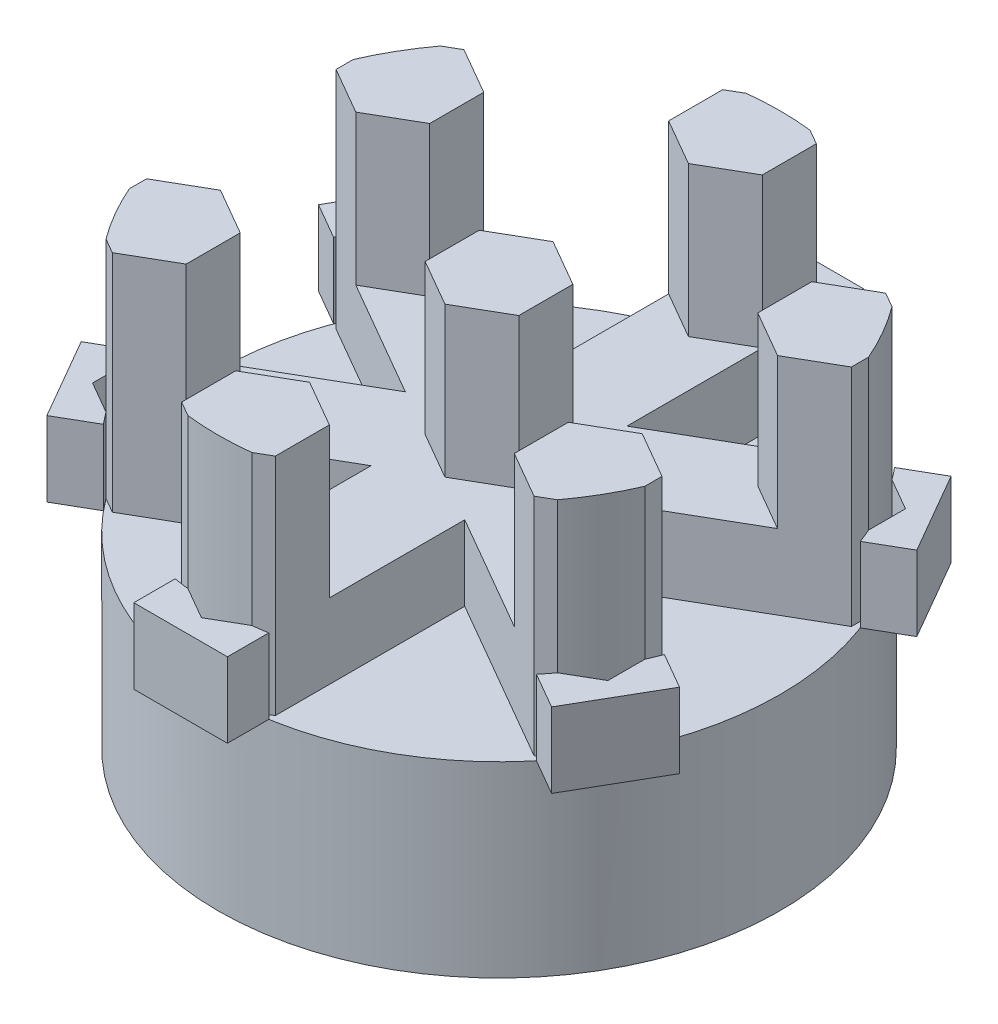
from build123d import *

# Parameters (mm, degrees)
SKETCH1_R           = 75
BOSS_EXTRUDE1_DEPTH = 50
BOSS_EXTRUDE2_DEPTH = 60
BOSS_EXTRUDE3_DEPTH = 20


with BuildPart() as part:
    # Sketch1 → Boss-Extrude1 (new body)
    with BuildSketch(Plane(origin=(0, 0, 0), x_dir=(1, 0, 0), z_dir=(0, 1, 0))):
        Circle(SKETCH1_R)
    extrude(amount=BOSS_EXTRUDE1_DEPTH)

    # Sketch2 → Boss-Extrude2 (add)
    with BuildSketch(Plane(origin=(0, 50, 0), x_dir=(1, 0, 0), z_dir=(0, 1, 0))):
        with BuildLine():
            Line((68.791651246, -29.878231521), (68.791651246, -25.283121635))
            Line((68.791651246, -25.283121635), (56.291651246, -18.06624327))
            Line((56.291651246, -18.06624327), (43.791651246, -25.283121635))
            Line((43.791651246, -25.283121635), (43.791651246, -39.716878365))
            Line((43.791651246, -39.716878365), (56.291651246, -46.93375673))
            Line((56.291651246, -46.93375673), (60.271133141, -44.636201787))
            ThreePointArc((60.271133141, -44.636201787), (64.951905284, -37.5), (68.791651246, -29.878231521))
        make_face()
        with BuildLine():
            Line((43.791651246, 25.283121635), (56.291651246, 18.06624327))
            Line((56.291651246, 18.06624327), (68.791651246, 25.283121635))
            Line((68.791651246, 25.283121635), (68.791651246, 29.878231521))
            ThreePointArc((68.791651246, 29.878231521), (64.951905284, 37.5), (60.271133141, 44.636201787))
            Line((60.271133141, 44.636201787), (56.291651246, 46.93375673))
            Line((56.291651246, 46.93375673), (43.791651246, 39.716878365))
            Line((43.791651246, 39.716878365), (43.791651246, 25.283121635))
        make_face()
        with BuildLine():
            Line((12.5, -72.216878365), (12.5, -57.783121635))
            Line((12.5, -57.783121635), (0, -50.56624327))
            Line((0, -50.56624327), (-12.5, -57.783121635))
            Line((-12.5, -57.783121635), (-12.5, -72.216878365))
            Line((-12.5, -72.216878365), (-8.520518105, -74.514433308))
            ThreePointArc((-8.520518105, -74.514433308), (0, -75), (8.520518105, -74.514433308))
            Line((8.520518105, -74.514433308), (12.5, -72.216878365))
        make_face()
        with BuildLine():
            Line((0, 50.56624327), (12.5, 57.783121635))
            Line((12.5, 57.783121635), (12.5, 72.216878365))
            Line((12.5, 72.216878365), (8.520518105, 74.514433308))
            ThreePointArc((8.520518105, 74.514433308), (0, 75), (-8.520518105, 74.514433308))
            Line((-8.520518105, 74.514433308), (-12.5, 72.216878365))
            Line((-12.5, 72.216878365), (-12.5, 57.783121635))
            Line((-12.5, 57.783121635), (0, 50.56624327))
        make_face()
        with BuildLine():
            Line((-56.291651246, -46.93375673), (-43.791651246, -39.716878365))
            Line((-43.791651246, -39.716878365), (-43.791651246, -25.283121635))
            Line((-43.791651246, -25.283121635), (-56.291651246, -18.06624327))
            Line((-56.291651246, -18.06624327), (-68.791651246, -25.283121635))
            Line((-68.791651246, -25.283121635), (-68.791651246, -29.878231521))
            ThreePointArc((-68.791651246, -29.878231521), (-64.951905284, -37.5), (-60.271133141, -44.636201787))
            Line((-60.271133141, -44.636201787), (-56.291651246, -46.93375673))
        make_face()
        with BuildLine():
            Line((-43.791651246, 25.283121635), (-43.791651246, 39.716878365))
            Line((-43.791651246, 39.716878365), (-56.291651246, 46.93375673))
            Line((-56.291651246, 46.93375673), (-60.271133141, 44.636201787))
            ThreePointArc((-60.271133141, 44.636201787), (-64.951905284, 37.5), (-68.791651246, 29.878231521))
            Line((-68.791651246, 29.878231521), (-68.791651246, 25.283121635))
            Line((-68.791651246, 25.283121635), (-56.291651246, 18.06624327))
            Line((-56.291651246, 18.06624327), (-43.791651246, 25.283121635))
        make_face()
        Polygon((0, 14.43375673), (-12.5, 7.216878365), (-12.5, -7.216878365), (0, -14.43375673), (12.5, -7.216878365), (12.5, 7.216878365), align=None)
    extrude(amount=BOSS_EXTRUDE2_DEPTH)

    # Sketch2_3 → Boss-Extrude3 (add)
    # profile 1 of 7: a face of its own
    with BuildSketch(Plane(origin=(0, 50, 0), x_dir=(1, 0, 0), z_dir=(0, 1, 0))):
        Polygon((43.791651246, -25.283121635), (56.291651246, -18.06624327), (25, 0), (56.291651246, 18.06624327), (43.791651246, 25.283121635), (43.791651246, 39.716878365), (12.5, 21.650635095), (12.5, 57.783121635), (0, 50.56624327), (-12.5, 57.783121635), (-12.5, 21.650635095), (-43.791651246, 39.716878365), (-43.791651246, 25.283121635), (-56.291651246, 18.06624327), (-25, 0), (-56.291651246, -18.06624327), (-43.791651246, -25.283121635), (-43.791651246, -39.716878365), (-12.5, -21.650635095), (-12.5, -57.783121635), (0, -50.56624327), (12.5, -57.783121635), (12.5, -21.650635095), (43.791651246, -39.716878365), align=None)
        Polygon((-12.5, -7.216878365), (-12.5, 7.216878365), (0, 14.43375673), (12.5, 7.216878365), (12.5, -7.216878365), (0, -14.43375673), align=None, mode=Mode.SUBTRACT)
    # profile 2 of 7: a face of its own
    with BuildSketch(Plane(origin=(0, 50, 0), x_dir=(1, 0, 0), z_dir=(0, 1, 0))):
        with BuildLine():
            Line((79.862159322, -31.674682453), (70.293442287, -26.150181097))
            ThreePointArc((70.293442287, -26.150181097), (69.567524038, -28.024268041), (68.791651246, -29.878231521))
            Line((68.791651246, -29.878231521), (68.791651246, -39.716878365))
            Line((68.791651246, -39.716878365), (60.271133141, -44.636201787))
            ThreePointArc((60.271133141, -44.636201787), (59.053490065, -46.235109075), (57.793442287, -47.800816192))
            Line((57.793442287, -47.800816192), (67.362159322, -53.325317547))
            Line((67.362159322, -53.325317547), (79.862159322, -31.674682453))
        make_face()
    # profile 3 of 7: a face of its own
    with BuildSketch(Plane(origin=(0, 50, 0), x_dir=(1, 0, 0), z_dir=(0, 1, 0))):
        with BuildLine():
            ThreePointArc((68.791651246, 29.878231521), (69.567524038, 28.024268041), (70.293442287, 26.150181097))
            Line((70.293442287, 26.150181097), (79.862159322, 31.674682453))
            Line((79.862159322, 31.674682453), (67.362159322, 53.325317547))
            Line((67.362159322, 53.325317547), (57.793442287, 47.800816192))
            ThreePointArc((57.793442287, 47.800816192), (59.053490065, 46.235109075), (60.271133141, 44.636201787))
            Line((60.271133141, 44.636201787), (68.791651246, 39.716878365))
            Line((68.791651246, 39.716878365), (68.791651246, 29.878231521))
        make_face()
    # profile 4 of 7: a face of its own
    with BuildSketch(Plane(origin=(0, 50, 0), x_dir=(1, 0, 0), z_dir=(0, 1, 0))):
        with BuildLine():
            Line((12.5, -85), (12.5, -73.950997289))
            ThreePointArc((12.5, -73.950997289), (10.514033973, -74.259377116), (8.520518105, -74.514433308))
            Line((8.520518105, -74.514433308), (0, -79.43375673))
            Line((0, -79.43375673), (-8.520518105, -74.514433308))
            ThreePointArc((-8.520518105, -74.514433308), (-10.514033973, -74.259377116), (-12.5, -73.950997289))
            Line((-12.5, -73.950997289), (-12.5, -85))
            Line((-12.5, -85), (12.5, -85))
        make_face()
    # profile 5 of 7: a face of its own
    with BuildSketch(Plane(origin=(0, 50, 0), x_dir=(1, 0, 0), z_dir=(0, 1, 0))):
        with BuildLine():
            ThreePointArc((8.520518105, 74.514433308), (10.514033973, 74.259377116), (12.5, 73.950997289))
            Line((12.5, 73.950997289), (12.5, 85))
            Line((12.5, 85), (-12.5, 85))
            Line((-12.5, 85), (-12.5, 73.950997289))
            ThreePointArc((-12.5, 73.950997289), (-10.514033973, 74.259377116), (-8.520518105, 74.514433308))
            Line((-8.520518105, 74.514433308), (0, 79.43375673))
            Line((0, 79.43375673), (8.520518105, 74.514433308))
        make_face()
    # profile 6 of 7: a face of its own
    with BuildSketch(Plane(origin=(0, 50, 0), x_dir=(1, 0, 0), z_dir=(0, 1, 0))):
        with BuildLine():
            Line((-67.362159322, -53.325317547), (-57.793442287, -47.800816192))
            ThreePointArc((-57.793442287, -47.800816192), (-59.053490065, -46.235109075), (-60.271133141, -44.636201787))
            Line((-60.271133141, -44.636201787), (-68.791651246, -39.716878365))
            Line((-68.791651246, -39.716878365), (-68.791651246, -29.878231521))
            ThreePointArc((-68.791651246, -29.878231521), (-69.567524038, -28.024268041), (-70.293442287, -26.150181097))
            Line((-70.293442287, -26.150181097), (-79.862159322, -31.674682453))
            Line((-79.862159322, -31.674682453), (-67.362159322, -53.325317547))
        make_face()
    # profile 7 of 7: a face of its own
    with BuildSketch(Plane(origin=(0, 50, 0), x_dir=(1, 0, 0), z_dir=(0, 1, 0))):
        with BuildLine():
            ThreePointArc((-60.271133141, 44.636201787), (-59.053490065, 46.235109075), (-57.793442287, 47.800816192))
            Line((-57.793442287, 47.800816192), (-67.362159322, 53.325317547))
            Line((-67.362159322, 53.325317547), (-79.862159322, 31.674682453))
            Line((-79.862159322, 31.674682453), (-70.293442287, 26.150181097))
            ThreePointArc((-70.293442287, 26.150181097), (-69.567524038, 28.024268041), (-68.791651246, 29.878231521))
            Line((-68.791651246, 29.878231521), (-68.791651246, 39.716878365))
            Line((-68.791651246, 39.716878365), (-60.271133141, 44.636201787))
        make_face()
    extrude(amount=BOSS_EXTRUDE3_DEPTH)


with BuildPart() as boss_extrude3_piece_1:
    # of the separate pieces the step leaves, piece 1, a body of its own (boss_extrude3_pieces)
    add(part.part.solids().sort_by_distance((75, 50, 0))[0])


with BuildPart() as boss_extrude3_piece_2:
    # of the separate pieces the step leaves, piece 2, a body of its own (boss_extrude3_pieces)
    add(part.part.solids().sort_by_distance((57.793442287, 70, -47.800816192))[0])


with BuildPart() as boss_extrude3_piece_3:
    # of the separate pieces the step leaves, piece 3, a body of its own (boss_extrude3_pieces)
    add(part.part.solids().sort_by_distance((70.293442287, 70, 26.150181097))[0])


with BuildPart() as boss_extrude3_piece_4:
    # of the separate pieces the step leaves, piece 4, a body of its own (boss_extrude3_pieces)
    add(part.part.solids().sort_by_distance((-12.5, 70, -73.950997289))[0])


with BuildPart() as boss_extrude3_piece_5:
    # of the separate pieces the step leaves, piece 5, a body of its own (boss_extrude3_pieces)
    add(part.part.solids().sort_by_distance((12.5, 70, 73.950997289))[0])


with BuildPart() as boss_extrude3_piece_6:
    # of the separate pieces the step leaves, piece 6, a body of its own (boss_extrude3_pieces)
    add(part.part.solids().sort_by_distance((-70.293442287, 70, -26.150181097))[0])


with BuildPart() as boss_extrude3_piece_7:
    # of the separate pieces the step leaves, piece 7, a body of its own (boss_extrude3_pieces)
    add(part.part.solids().sort_by_distance((-57.793442287, 70, 47.800816192))[0])


solid = Compound([boss_extrude3_piece_1.part, boss_extrude3_piece_2.part, boss_extrude3_piece_3.part, boss_extrude3_piece_4.part, boss_extrude3_piece_5.part, boss_extrude3_piece_6.part, boss_extrude3_piece_7.part])
